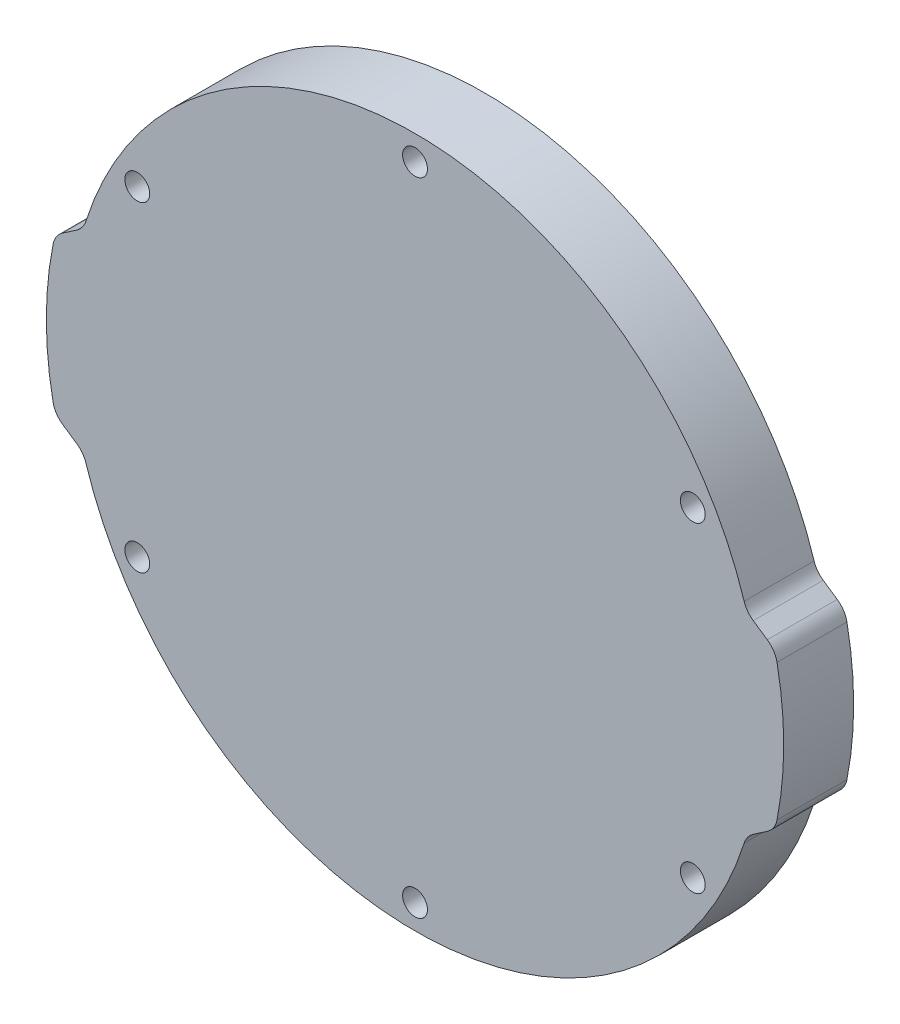
from build123d import *

# Parameters (mm, degrees)
SKETCH1_R           = 1.6
BOSS_EXTRUDE1_DEPTH = 9
FILLET1_R           = 3


with BuildPart() as part:
    # Sketch1 → Boss-Extrude1 (new body)
    with BuildSketch(Plane.XY):
        with BuildLine():
            Line((-46.324821937, 10), (-42.656212912, 12.5))
            ThreePointArc((-42.656212912, 12.5), (0, 44.45), (42.656212912, 12.5))
            Line((42.656212912, 12.5), (46.324821937, 10))
            ThreePointArc((46.324821937, 10), (47.45, 0), (46.324821937, -10))
            Line((46.324821937, -10), (42.656212912, -12.5))
            ThreePointArc((42.656212912, -12.5), (0, -44.45), (-42.656212912, -12.5))
            Line((-42.656212912, -12.5), (-46.324821937, -10))
            ThreePointArc((-46.324821937, -10), (-47.45, 0), (-46.324821937, 10))
        make_face()
        with Locations((0, 41.275)):
            Circle(SKETCH1_R, mode=Mode.SUBTRACT)
        with Locations((35.745198541, 20.6375)):
            Circle(SKETCH1_R, mode=Mode.SUBTRACT)
        with Locations((35.745198541, -20.6375)):
            Circle(SKETCH1_R, mode=Mode.SUBTRACT)
        with Locations((0, -41.275)):
            Circle(SKETCH1_R, mode=Mode.SUBTRACT)
        with Locations((-35.745198541, -20.6375)):
            Circle(SKETCH1_R, mode=Mode.SUBTRACT)
        with Locations((-35.745198541, 20.6375)):
            Circle(SKETCH1_R, mode=Mode.SUBTRACT)
    extrude(amount=BOSS_EXTRUDE1_DEPTH)

    # Fillet1
    fillet1_edges = [part.edges().sort_by_distance(p)[0] for p in [
        (46.324821937, -10, 4.5),
        (42.656212912, -12.5, 4.5),
        (-42.656212912, -12.5, 4.5),
        (-46.324821937, -10, 4.5),
        (-46.324821937, 10, 4.5),
        (-42.656212912, 12.5, 4.5),
        (42.656212912, 12.5, 4.5),
        (46.324821937, 10, 4.5),
    ]]
    fillet(fillet1_edges, radius=FILLET1_R)


solid = part.part
